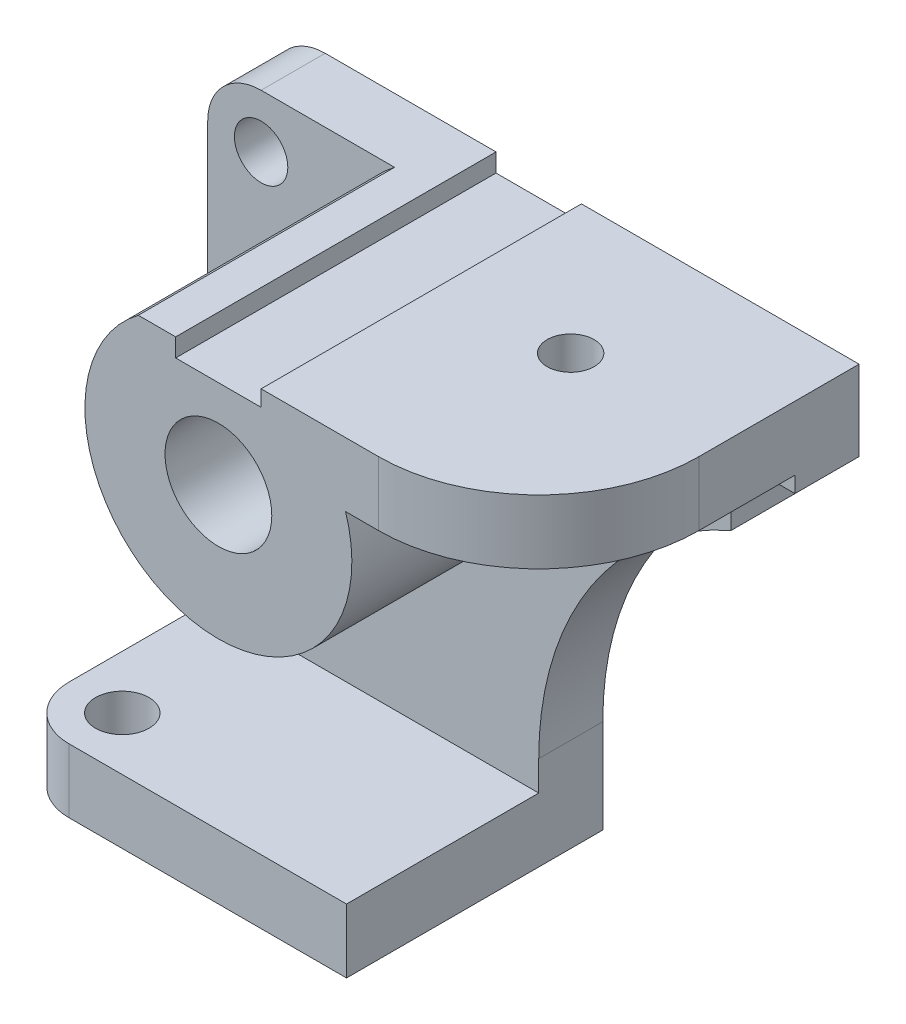
from build123d import *

# Parameters (mm, degrees)
SKETCH2_R           = 5
SKETCH2_R_2         = 10
BOSS_EXTRUDE2_DEPTH = 12
SKETCH3_R           = 5
BOSS_EXTRUDE3_DEPTH = 12
SKETCH4_R           = 10
BOSS_EXTRUDE4_DEPTH = 48
BOSS_EXTRUDE5_DEPTH = 12
SKETCH6_R           = 4.4
CUT_EXTRUDE1_DEPTH  = 100.572444927


with BuildPart() as part:
    # Sketch2 → Boss-Extrude2 (new body)
    with BuildSketch(Plane.XY):
        with BuildLine():
            Line((0, 0), (-50, 0))
            Line((-50, 0), (-50, 90))
            ThreePointArc((-50, 90), (-47.071067812, 97.071067812), (-40, 100))
            Line((-40, 100), (-8, 100))
            Line((-8, 100), (-8, 96.572444927))
            Line((-8, 96.572444927), (8, 96.572444927))
            Line((8, 96.572444927), (8, 99.572444927))
            Line((8, 99.572444927), (60, 99.572444927))
            Line((60, 99.572444927), (60, 84.572444927))
            Line((60, 84.572444927), (48, 84.572444927))
            Line((48, 84.572444927), (48, 72.572444927))
            ThreePointArc((48, 72.572444927), (21.800398408, 50.444890038), (12, 17.581536588))
            Line((12, 17.581536588), (12, 0))
            Line((12, 0), (0, 0))
        make_face()
        with Locations((-40, 90)):
            Circle(SKETCH2_R, mode=Mode.SUBTRACT)
        with Locations((0, 80)):
            Circle(SKETCH2_R_2, mode=Mode.SUBTRACT)
    extrude(amount=BOSS_EXTRUDE2_DEPTH)

    # Sketch3 → Boss-Extrude3 (add)
    with BuildSketch(Plane.XZ):
        with BuildLine():
            Line((-50, 0), (-50, 38))
            ThreePointArc((-50, 38), (-47.071067812, 45.071067812), (-40, 48))
            Line((-40, 48), (12, 48))
            Line((12, 48), (12, 0))
            Line((12, 0), (-50, 0))
        make_face()
        with Locations((-40, 38)):
            Circle(SKETCH3_R, mode=Mode.SUBTRACT)
    extrude(amount=-BOSS_EXTRUDE3_DEPTH)

    # Sketch4 → Boss-Extrude4 (add)
    with BuildSketch(Plane.XY.offset(12)):
        with BuildLine():
            ThreePointArc((-15, 100), (-0.349804116, 55.002447378), (15.553758374, 99.572444927))
            Line((15.553758374, 99.572444927), (8, 99.572444927))
            Line((8, 99.572444927), (8, 96.572444927))
            Line((8, 96.572444927), (-8, 96.572444927))
            Line((-8, 96.572444927), (-8, 100))
            Line((-8, 100), (-15, 100))
        make_face()
        with Locations((0, 80)):
            Circle(SKETCH4_R, mode=Mode.SUBTRACT)
    extrude(amount=BOSS_EXTRUDE4_DEPTH)

    # Sketch5 → Boss-Extrude5 (add)
    with BuildSketch(Plane(origin=(0, 99.572444927, 0), x_dir=(1, 0, 0), z_dir=(0, 1, 0))):
        with BuildLine():
            Line((8, -60), (8, 0))
            Line((8, 0), (60, 0))
            Line((60, 0), (60, -12))
            Line((60, -12), (60, -30))
            ThreePointArc((60, -30), (51.213203436, -51.213203436), (30, -60))
            Line((30, -60), (8, -60))
        make_face()
    extrude(amount=-BOSS_EXTRUDE5_DEPTH)

    # Sketch6 → Cut-Extrude1 (cut, through all)
    with BuildSketch(Plane(origin=(0, 99.572444927, 0), x_dir=(1, 0, 0), z_dir=(0, 1, 0))):
        with Locations((31.202070331, -25.224562722)):
            Circle(SKETCH6_R)
    extrude(amount=-CUT_EXTRUDE1_DEPTH, mode=Mode.SUBTRACT)


solid = part.part
